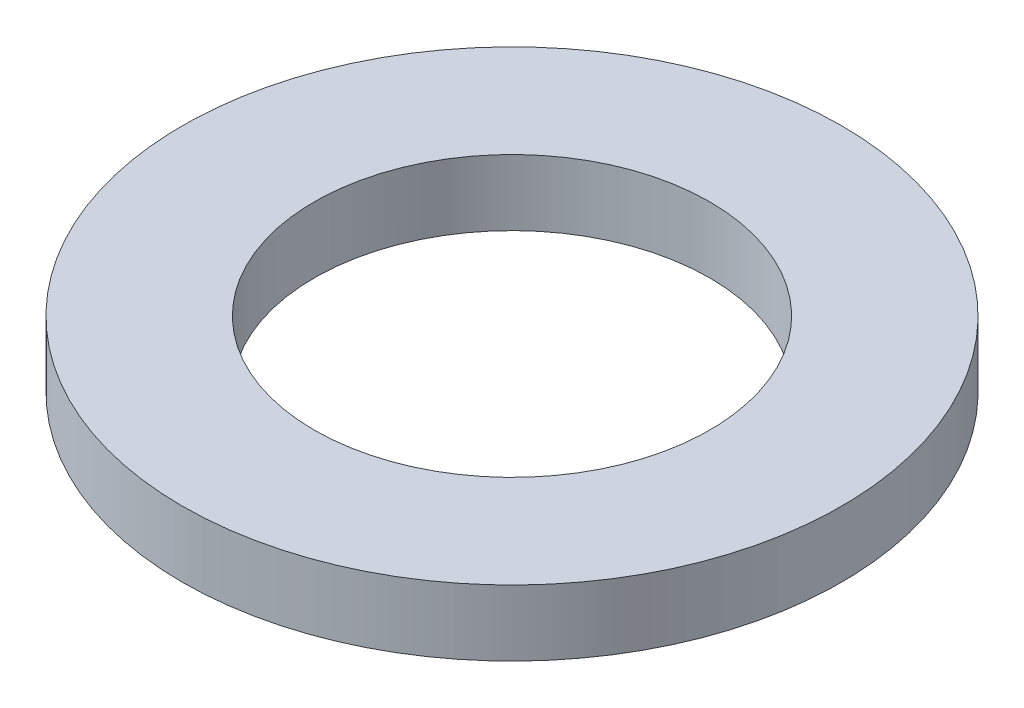
from build123d import *

# Parameters (mm, degrees)
SKETCH_1_R          = 15
EXTRUDE_1_DEPTH     = 3
SKETCH_2_R          = 9
CUT_EXTRUDE_1_DEPTH = 24.5


with BuildPart() as part:
    # 草图1 → 凸台-拉伸1 (new body)
    with BuildSketch(Plane(origin=(0, 0, 0), x_dir=(1, 0, 0), z_dir=(0, 1, 0))):
        Circle(SKETCH_1_R)
    extrude(amount=EXTRUDE_1_DEPTH)

    # 草图2 → 切除-拉伸1 (cut)
    with BuildSketch(Plane.XZ):
        Circle(SKETCH_2_R)
    extrude(amount=-CUT_EXTRUDE_1_DEPTH, mode=Mode.SUBTRACT)


solid = part.part
